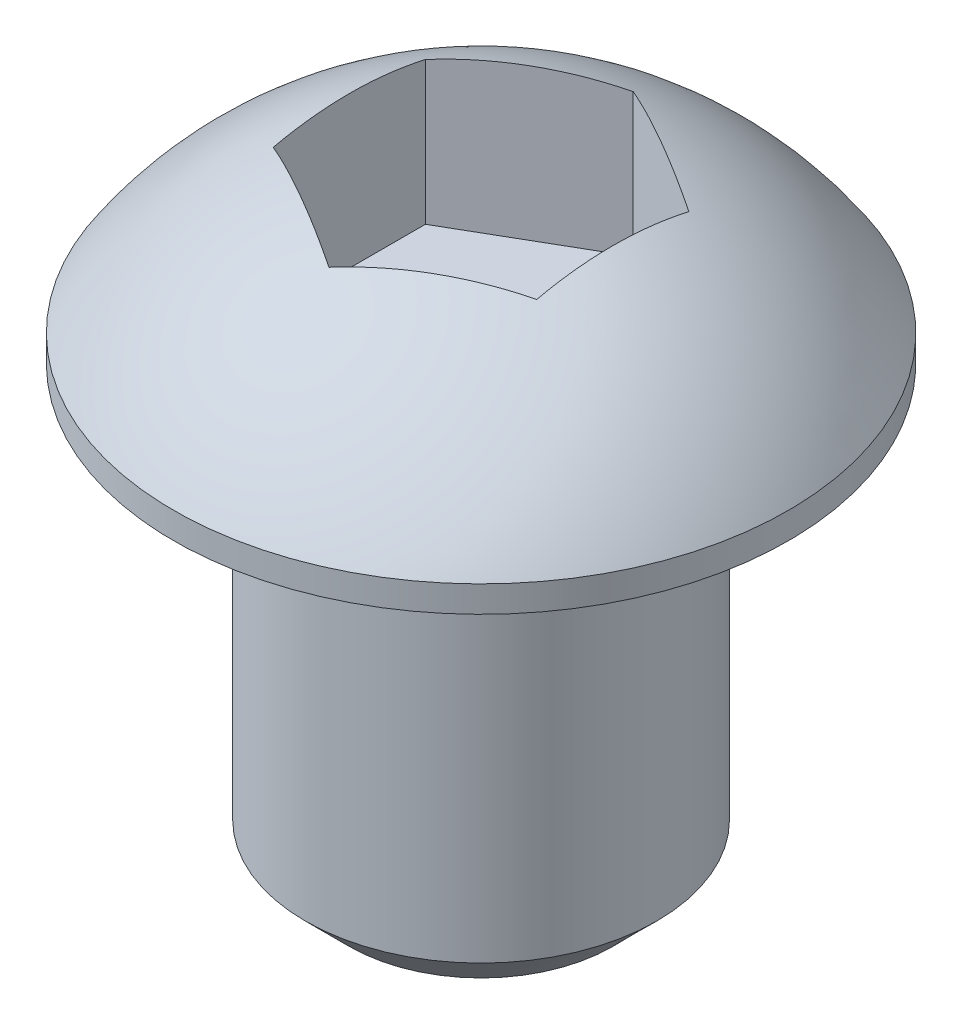
from build123d import *

# Parameters (mm, degrees)
SKETCH1_R           = 2
BOSS_EXTRUDE3_DEPTH = 5
CHAMFER2_SIZE       = 0.5
CUT_EXTRUDE2_DEPTH  = 2


with BuildPart() as part:
    # Sketch1 → Boss-Extrude3 (new body)
    with BuildSketch(Plane(origin=(0, 0, 0), x_dir=(1, 0, 0), z_dir=(0, 1, 0))):
        Circle(SKETCH1_R)
    extrude(amount=-BOSS_EXTRUDE3_DEPTH)

    # Sketch3 → Revolve2 (revolve)
    with BuildSketch(Plane.XY):
        with BuildLine():
            Line((-3.5, 0), (-3.5, 0.3))
            ThreePointArc((-3.5, 0.3), (-1.988393808, 1.6859585), (0, 2.188078318))
            Line((0, 2.188078318), (0, 0))
            Line((0, 0), (-3.5, 0))
        make_face()
    revolve(axis=Axis((0, -2, 0), (0, 1, 0)))

    # Chamfer2
    chamfer2_edges = [part.edges().sort_by_distance(p)[0] for p in [
        (-2, -5, 0),
    ]]
    chamfer(chamfer2_edges, length=CHAMFER2_SIZE)

    # Sketch4 → Cut-Extrude2 (cut)
    with BuildSketch(Plane(origin=(0, 2.188078318, 0), x_dir=(1, 0, 0), z_dir=(0, 1, 0))):
        Polygon((0, 1.732050808), (-1.5, 0.866025404), (-1.5, -0.866025404), (0, -1.732050808), (1.5, -0.866025404), (1.5, 0.866025404), align=None)
    extrude(amount=-CUT_EXTRUDE2_DEPTH, mode=Mode.SUBTRACT)


solid = part.part
